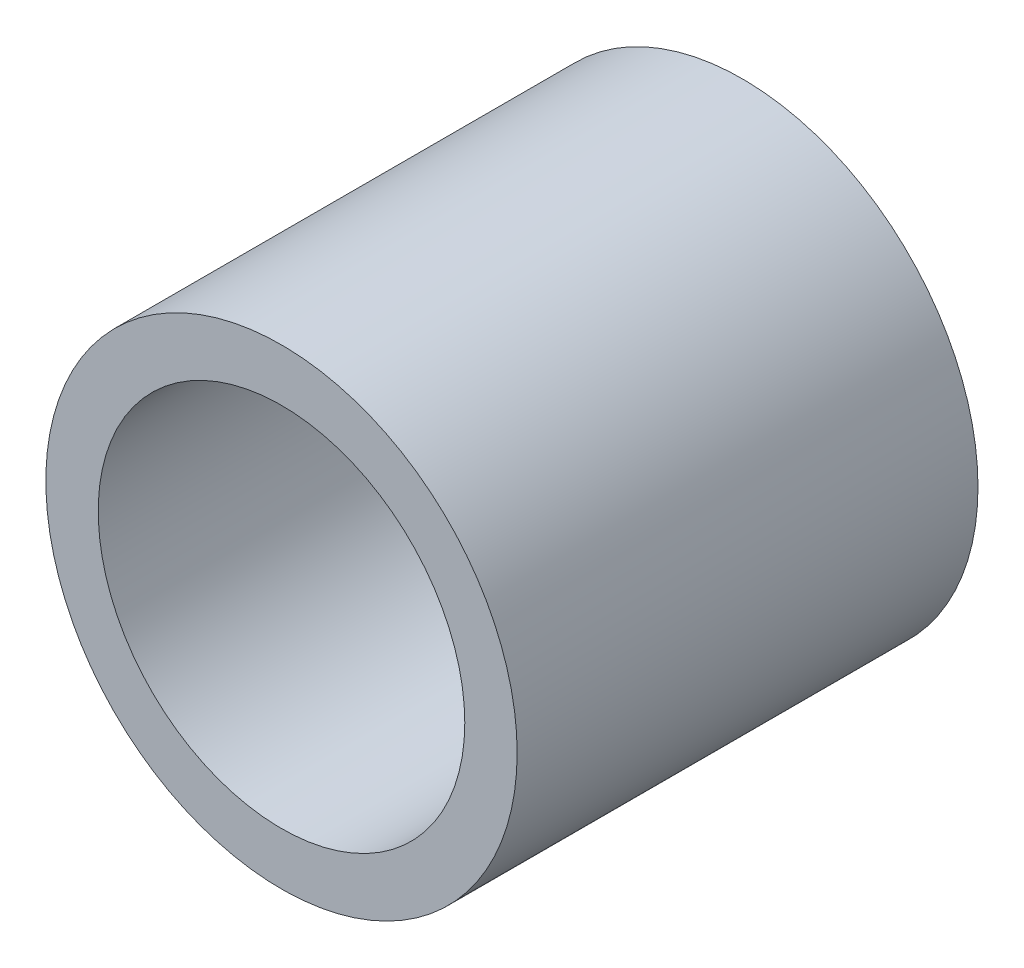
from build123d import *

# Parameters (mm, degrees)
ESQUISSE1_R      = 5.625
ESQUISSE1_R_2    = 4.375
EXTRUSION1_DEPTH = 11


with BuildPart() as part:
    # Esquisse1 → Extrusion1 (new body)
    with BuildSketch(Plane.XY):
        Circle(ESQUISSE1_R)
        Circle(ESQUISSE1_R_2, mode=Mode.SUBTRACT)
    extrude(amount=EXTRUSION1_DEPTH)


solid = part.part
